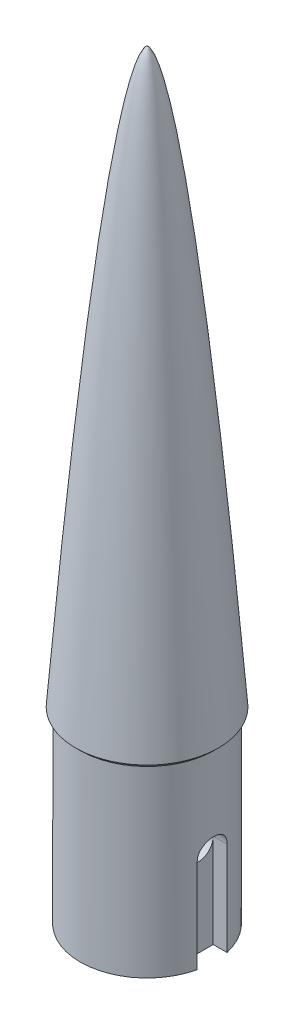
from build123d import *

# Parameters (mm, degrees)
SKETCH1_R               = 8.895
BOSS_EXTRUDE1_DEPTH     = 25
CUT_EXTRUDE1_DEPTH      = 12.5
SKETCH3_R               = 1.984375
CUT_EXTRUDE2_DEPTH      = 9.895
CUT_EXTRUDE2_DEPTH_BACK = 9.895
CHAMFER1_SIZE           = 0.6


with BuildPart() as part:
    # Sketch1 → Boss-Extrude1 (new body)
    with BuildSketch(Plane(origin=(0, 0, 0), x_dir=(1, 0, 0), z_dir=(0, 1, 0))):
        Circle(SKETCH1_R)
    extrude(amount=-BOSS_EXTRUDE1_DEPTH)

    # Sketch2 → Cut-Extrude1 (cut)
    with BuildSketch(Plane.XZ.offset(25)):
        with BuildLine():
            Line((-6.83125, 1.984375), (-6.83125, -1.984375))
            Line((-6.83125, -1.984375), (-8.670829306, -1.984375))
            ThreePointArc((-8.670829306, -1.984375), (-8.895, 0), (-8.670829306, 1.984375))
            Line((-8.670829306, 1.984375), (-6.83125, 1.984375))
        make_face()
    cut_extrude1 = extrude(amount=-CUT_EXTRUDE1_DEPTH, mode=Mode.SUBTRACT)

    # Mirror1: Cut-Extrude1 across plane
    add(cut_extrude1.mirror(Plane(origin=(0, 0, 0), x_dir=(0, 0, 1), z_dir=(1, 0, 0))), mode=Mode.SUBTRACT)

    # Sketch3 → Cut-Extrude2 (cut, two sides)
    with BuildSketch(Plane(origin=(0, 0, 0), x_dir=(0, 0, -1), z_dir=(1, 0, 0))) as cut_extrude2_sk:
        with Locations((0, -12.5)):
            Circle(SKETCH3_R)
    extrude(amount=CUT_EXTRUDE2_DEPTH, mode=Mode.SUBTRACT)
    extrude(cut_extrude2_sk.sketch, amount=-CUT_EXTRUDE2_DEPTH_BACK, mode=Mode.SUBTRACT)

    # Sketch4 → Revolve1 (revolve)
    with BuildSketch(Plane.XY):
        with BuildLine():
            Line((0, 0), (0, 76.2))
            add(Edge.make_bspline(
                [(0, 76.2), (0.010785041, 76.199224813), (0.031898851, 76.195655683), (0.072292948, 76.180192568), (0.120867926, 76.149408415), (0.16893656, 76.109505667), (0.219506214, 76.05859599), (0.270891595, 75.999075831), (0.33405813, 75.915307947), (0.416902674, 75.788683792), (0.530129314, 75.587496608), (0.690806004, 75.250371079), (0.925151077, 74.660400515), (1.28066013, 73.56410381), (1.819345698, 71.484532143), (2.494562294, 68.169675275), (3.229107388, 63.761120823), (3.974148921, 58.507567912), (4.671648215, 52.966650055), (5.309955775, 47.384032694), (5.89808978, 41.850390189), (6.456372381, 36.225635174), (6.974392848, 30.74087905), (7.485193122, 25.019380562), (7.946052453, 19.68165029), (8.436147301, 13.706913443), (8.831540425, 8.78213491), (9.214950637, 3.783393938), (9.405019243, 1.269742765), (9.500000001, 0)],
                knots=[0, 0, 0, 0, 0, 0.000506263, 0.001012527, 0.002025053, 0.002702132, 0.00345017, 0.004398317, 0.005734537, 0.007654734, 0.010586496, 0.015298636, 0.023344234, 0.03763286, 0.06493253, 0.116773094, 0.182858951, 0.248944817, 0.315030683, 0.381116549, 0.447202415, 0.513288281, 0.579374148, 0.645460014, 0.71154588, 0.777631747, 0.843717613, 0.909803479, 0.909803479, 0.909803479, 0.909803479, 0.909803479], degree=4))
            Line((9.500000001, 0), (0, 0))
        make_face()
    revolve(axis=Axis((0, 0, 0), (0, 1, 0)))

    # Chamfer1
    chamfer1_edges = [part.edges().sort_by_distance(p)[0] for p in [
        (-8.895, 0, 0),
    ]]
    chamfer(chamfer1_edges, length=CHAMFER1_SIZE)


solid = part.part
